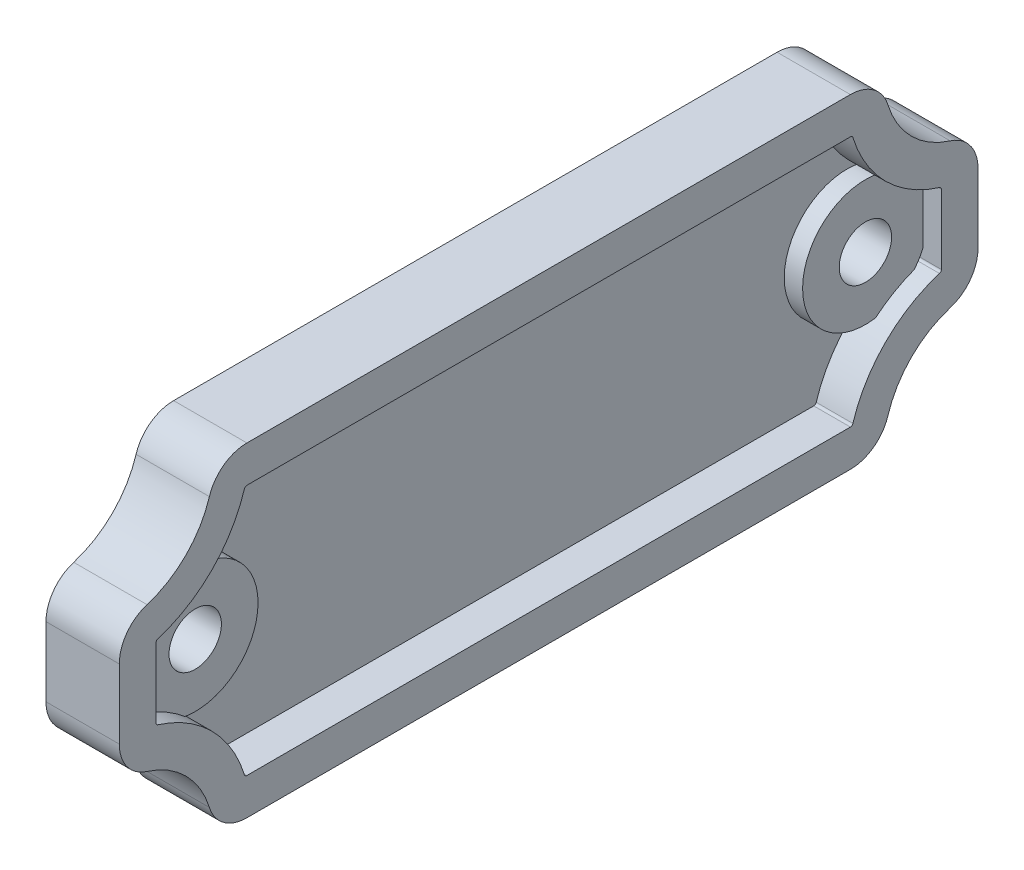
from build123d import *

# Parameters (mm, degrees)
SKETCH1_R           = 2.5
BOSS_EXTRUDE1_DEPTH = 7
CUT_EXTRUDE1_DEPTH  = 3.5
SKETCH7_R           = 6
SKETCH7_R_2         = 2.5
BOSS_EXTRUDE2_DEPTH = 5.25
SKETCH8_R           = 6
SKETCH8_R_2         = 2.5
BOSS_EXTRUDE3_DEPTH = 1.75


with BuildPart() as part:
    # Sketch1 → Boss-Extrude1 (new body)
    with BuildSketch(Plane(origin=(0, 0, 0), x_dir=(0, 0, -1), z_dir=(1, 0, 0))):
        with BuildLine():
            Line((28.813942393, -15.5), (-28.813942393, -15.5))
            ThreePointArc((-28.813942393, -15.5), (-31.041774365, -14.76649875), (-32.398076983, -12.852941176))
            ThreePointArc((-32.398076983, -12.852941176), (-34.636038969, -9.136038969), (-38.352941176, -6.898076983))
            ThreePointArc((-38.352941176, -6.898076983), (-40.26649875, -5.541774365), (-41, -3.313942393))
            Line((-41, -3.313942393), (-41, 3.313942393))
            ThreePointArc((-41, 3.313942393), (-40.26649875, 5.541774365), (-38.352941176, 6.898076983))
            ThreePointArc((-38.352941176, 6.898076983), (-34.636038969, 9.136038969), (-32.398076983, 12.852941176))
            ThreePointArc((-32.398076983, 12.852941176), (-31.041774365, 14.76649875), (-28.813942393, 15.5))
            Line((-28.813942393, 15.5), (28.813942393, 15.5))
            ThreePointArc((28.813942393, 15.5), (31.041774365, 14.76649875), (32.398076983, 12.852941176))
            ThreePointArc((32.398076983, 12.852941176), (34.636038969, 9.136038969), (38.352941176, 6.898076983))
            ThreePointArc((38.352941176, 6.898076983), (40.26649875, 5.541774365), (41, 3.313942393))
            Line((41, 3.313942393), (41, -3.313942393))
            ThreePointArc((41, -3.313942393), (40.26649875, -5.541774365), (38.352941176, -6.898076983))
            ThreePointArc((38.352941176, -6.898076983), (34.636038969, -9.136038969), (32.398076983, -12.852941176))
            ThreePointArc((32.398076983, -12.852941176), (31.041774365, -14.76649875), (28.813942393, -15.5))
        make_face()
        with Locations((-32, 0)):
            Circle(SKETCH1_R, mode=Mode.SUBTRACT)
        with Locations((32, 0)):
            Circle(SKETCH1_R, mode=Mode.SUBTRACT)
    extrude(amount=BOSS_EXTRUDE1_DEPTH)

    # Sketch6 → Cut-Extrude1 (cut)
    with BuildSketch(Plane(origin=(7, 0, 0), x_dir=(0, 0, -1), z_dir=(1, 0, 0))):
        with BuildLine():
            Line((28.813942393, 12), (-28.813942393, 12))
            ThreePointArc((-28.813942393, 12), (-28.962464524, 11.951099917), (-29.052884699, 11.823529412))
            ThreePointArc((-29.052884699, 11.823529412), (-32.161165235, 6.661165235), (-37.323529412, 3.552884699))
            ThreePointArc((-37.323529412, 3.552884699), (-37.451099917, 3.462464524), (-37.5, 3.313942393))
            Line((-37.5, 3.313942393), (-37.5, -3.313942393))
            ThreePointArc((-37.5, -3.313942393), (-37.451099917, -3.462464524), (-37.323529412, -3.552884699))
            ThreePointArc((-37.323529412, -3.552884699), (-32.161165235, -6.661165235), (-29.052884699, -11.823529412))
            ThreePointArc((-29.052884699, -11.823529412), (-28.962464524, -11.951099917), (-28.813942393, -12))
            Line((-28.813942393, -12), (28.813942393, -12))
            ThreePointArc((28.813942393, -12), (28.962464524, -11.951099917), (29.052884699, -11.823529412))
            ThreePointArc((29.052884699, -11.823529412), (32.161165235, -6.661165235), (37.323529412, -3.552884699))
            ThreePointArc((37.323529412, -3.552884699), (37.451099917, -3.462464524), (37.5, -3.313942393))
            Line((37.5, -3.313942393), (37.5, 3.313942393))
            ThreePointArc((37.5, 3.313942393), (37.451099917, 3.462464524), (37.323529412, 3.552884699))
            ThreePointArc((37.323529412, 3.552884699), (32.161165235, 6.661165235), (29.052884699, 11.823529412))
            ThreePointArc((29.052884699, 11.823529412), (28.962464524, 11.951099917), (28.813942393, 12))
        make_face()
    extrude(amount=-CUT_EXTRUDE1_DEPTH, mode=Mode.SUBTRACT)

    # Sketch7 → Boss-Extrude2 (add)
    with BuildSketch(Plane(origin=(3.5, 0, 0), x_dir=(0, 0, -1), z_dir=(1, 0, 0))):
        with Locations((32, 0)):
            Circle(SKETCH7_R)
        with Locations((32, 0)):
            Circle(SKETCH7_R_2, mode=Mode.SUBTRACT)
    boss_extrude2 = extrude(amount=-BOSS_EXTRUDE2_DEPTH)

    # Mirror1: Boss-Extrude2 across plane
    add(boss_extrude2.mirror(Plane.XY))

    # Sketch8 → Boss-Extrude3 (add)
    with BuildSketch(Plane(origin=(3.5, 0, 0), x_dir=(0, 0, -1), z_dir=(1, 0, 0))):
        with Locations((32, 0)):
            Circle(SKETCH8_R)
        with Locations((32, 0)):
            Circle(SKETCH8_R_2, mode=Mode.SUBTRACT)
    boss_extrude3 = extrude(amount=BOSS_EXTRUDE3_DEPTH)

    # Mirror2: Boss-Extrude3 across plane
    add(boss_extrude3.mirror(Plane.XY))


solid = part.part
